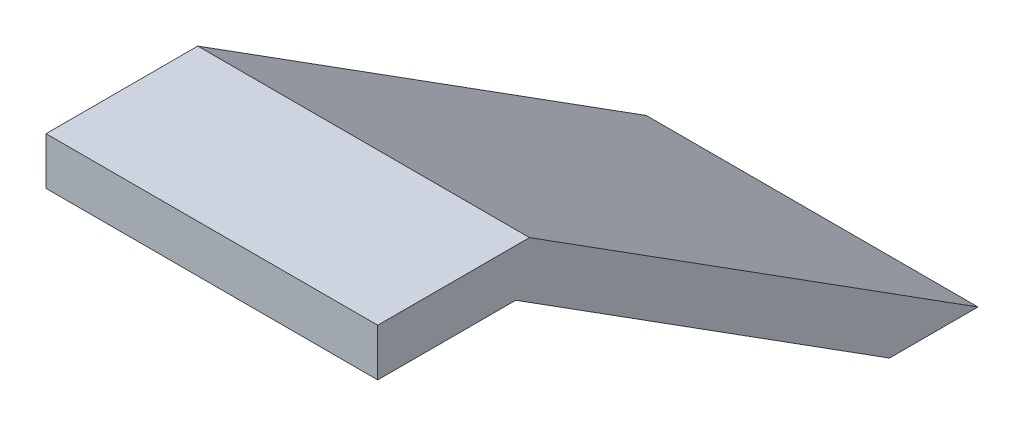
from build123d import *

# Parameters (mm, degrees)
CROQUIS2_W                 = 43
CROQUIS2_H                 = 30
SALIENTE_EXTRUIR1_DEPTH    = 30
CROQUIS3_W                 = 42.529407755
CROQUIS3_H                 = 25.558495791
CORTAR_EXTRUIR1_DEPTH      = 30
CORTAR_EXTRUIR2_START      = -7.5
CORTAR_EXTRUIR2_DEPTH      = 15
CORTAR_EXTRUIR4_DEPTH      = 4.5
CORTAR_EXTRUIR5_DEPTH      = 4.5
REDONDEO1_R                = 3
CROQUIS8_W                 = 15
CROQUIS8_H                 = 32.397186909
CORTAR_EXTRUIR6_DEPTH      = 4.5
CROQUIS9_W                 = 120.283196461
CROQUIS9_H                 = 78.810135234
CORTAR_EXTRUIR7_DEPTH      = 22.5
CORTAR_EXTRUIR9_DEPTH      = 22.5
CORTAR_EXTRUIR9_DEPTH_BACK = 29.5


with BuildPart() as part:
    # Croquis2 → Saliente-Extruir1 (new body)
    with BuildSketch(Plane(origin=(0, 0, 0), x_dir=(0, 0, -1), z_dir=(1, 0, 0))):
        with Locations((-19.783269962, -13.522813688)):
            Rectangle(CROQUIS2_W, CROQUIS2_H)
    extrude(amount=SALIENTE_EXTRUIR1_DEPTH)

    # Croquis3 → Cortar-Extruir1 (cut)
    with BuildSketch(Plane(origin=(30, 0, 0), x_dir=(0, 0, -1), z_dir=(1, 0, 0))):
        with Locations((-17.018566085, -31.302061584)):
            Rectangle(CROQUIS3_W, CROQUIS3_H)
        Polygon((-31.675073764, 1.477186312), (-3.283269962, -16.522813688), (1.716730038, -16.522813688), (1.716730038, 1.477186312), align=None)
    extrude(amount=-CORTAR_EXTRUIR1_DEPTH, mode=Mode.SUBTRACT)

    # Croquis4 → Cortar-Extruir2 (cut)
    with BuildSketch(Plane(origin=(30, 0, 0), x_dir=(0, 0, -1), z_dir=(1, 0, 0)).offset(CORTAR_EXTRUIR2_START)):
        Polygon((-41.283269962, -1.522813688), (-32.545919554, -1.522813688), (-8.886083053, -16.522813688), (-41.283269962, -16.522813688), align=None)
    extrude(amount=-CORTAR_EXTRUIR2_DEPTH, mode=Mode.SUBTRACT)

    # Croquis5 → Cortar-Extruir4 (cut)
    with BuildSketch(Plane(origin=(30, 0, 0), x_dir=(0, 0, -1), z_dir=(1, 0, 0))):
        Polygon((-3.283269962, -16.522813688), (-41.283269962, -16.522813688), (-41.283269962, 1.477186312), (-31.675073764, 1.477186312), align=None)
    extrude(amount=-CORTAR_EXTRUIR4_DEPTH, mode=Mode.SUBTRACT)

    # Croquis6 → Cortar-Extruir5 (cut)
    with BuildSketch(Plane.ZY):
        Polygon((3.283269962, -16.522813688), (41.283269962, -16.522813688), (41.283269962, 1.477186312), (31.675073764, 1.477186312), align=None)
    extrude(amount=-CORTAR_EXTRUIR5_DEPTH, mode=Mode.SUBTRACT)

    # Redondeo1
    redondeo1_edges = [part.edges().sort_by_distance(p)[0] for p in [
        (0, -17.522813688, -1.716730038),
        (30, -17.522813688, -1.716730038),
    ]]
    fillet(redondeo1_edges, radius=REDONDEO1_R)

    # Croquis8 → Cortar-Extruir6 (cut)
    with BuildSketch(Plane(origin=(0, -16.522813688, 0), x_dir=(1, 0, 0), z_dir=(0, 1, 0))):
        with Locations((15, -25.084676508)):
            Rectangle(CROQUIS8_W, CROQUIS8_H)
    extrude(amount=-CORTAR_EXTRUIR6_DEPTH, mode=Mode.SUBTRACT)

    # Croquis9 → Cortar-Extruir7 (cut)
    with BuildSketch(Plane.XZ.offset(18.522813688)):
        with Locations((17.6156444, 62.089659259)):
            Rectangle(CROQUIS9_W, CROQUIS9_H)
    extrude(amount=CORTAR_EXTRUIR7_DEPTH, mode=Mode.SUBTRACT)

    # Croquis10 → Cortar-Extruir9 (cut, two sides)
    with BuildSketch(Plane(origin=(25.5, 0, 0), x_dir=(0, 0, -1), z_dir=(1, 0, 0))) as cortar_extruir9_sk:
        Polygon((-41.283269962, -1.522813688), (-32.545919554, -1.522813688), (-8.886083053, -16.522813688), (1.716730038, -16.522813688), (18.108947867, -28.45757264), (-61.799912443, -25.241788427), align=None)
    extrude(amount=CORTAR_EXTRUIR9_DEPTH, mode=Mode.SUBTRACT)
    extrude(cortar_extruir9_sk.sketch, amount=-CORTAR_EXTRUIR9_DEPTH_BACK, mode=Mode.SUBTRACT)


solid = part.part
